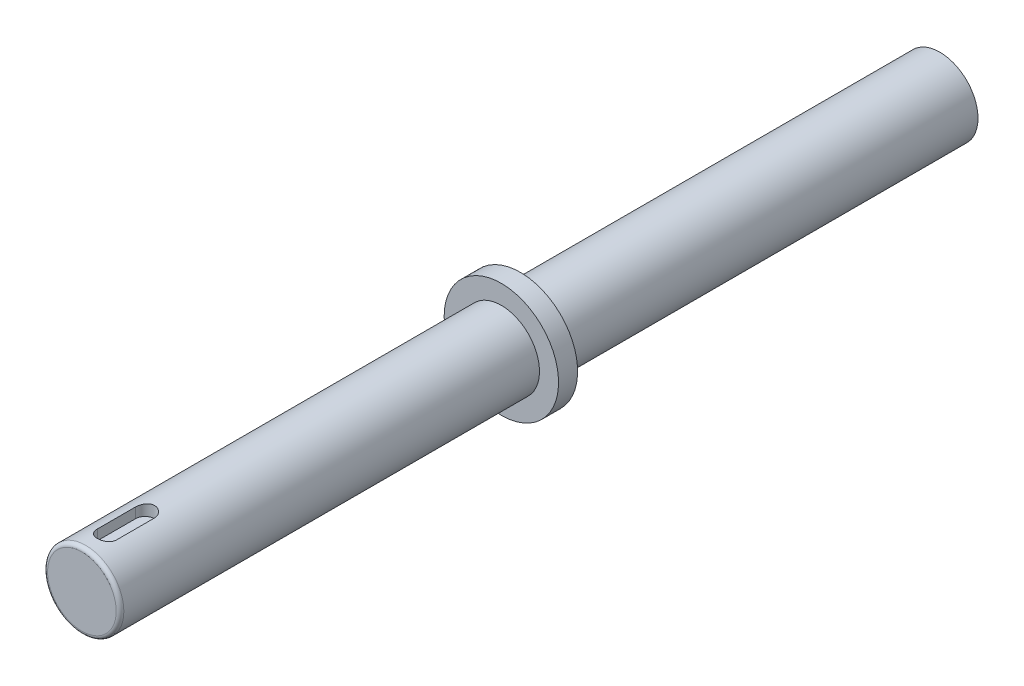
from build123d import *

# Parameters (mm, degrees)
SKETCH_1_R          = 10
EXTRUDE_1_DEPTH     = 225
SKETCH_2_R          = 15
EXTRUDE_2_DEPTH     = 5
CUT_EXTRUDE_1_DEPTH = 18
FILLET_1_R          = 1


with BuildPart() as part:
    # 草图1 → 凸台-拉伸1 (new body)
    with BuildSketch(Plane.XY):
        Circle(SKETCH_1_R)
    extrude(amount=EXTRUDE_1_DEPTH)

    # 草图2 → 凸台-拉伸2 (add)
    with BuildSketch(Plane(origin=(0, 0, 110), x_dir=(-1, 0, 0), z_dir=(0, 0, -1))):
        Circle(SKETCH_2_R)
    extrude(amount=-EXTRUDE_2_DEPTH)

    # 草图4 → 切除-拉伸1 (cut)
    with BuildSketch(Plane(origin=(0, 7, 0), x_dir=(-1, 0, 0), z_dir=(0, 1, 0))):
        with BuildLine():
            Line((-2.5, 208.431386243), (-2.5, 218.431386243))
            ThreePointArc((-2.5, 218.431386243), (0, 220.931386243), (2.5, 218.431386243))
            Line((2.5, 218.431386243), (2.5, 208.431386243))
            ThreePointArc((2.5, 208.431386243), (0, 205.931386243), (-2.5, 208.431386243))
        make_face()
    extrude(amount=CUT_EXTRUDE_1_DEPTH, mode=Mode.SUBTRACT)

    # 圆角1
    fillet_1_edges = [part.edges().sort_by_distance(p)[0] for p in [
        (-10, 0, 225),
    ]]
    fillet(fillet_1_edges, radius=FILLET_1_R)


solid = part.part
